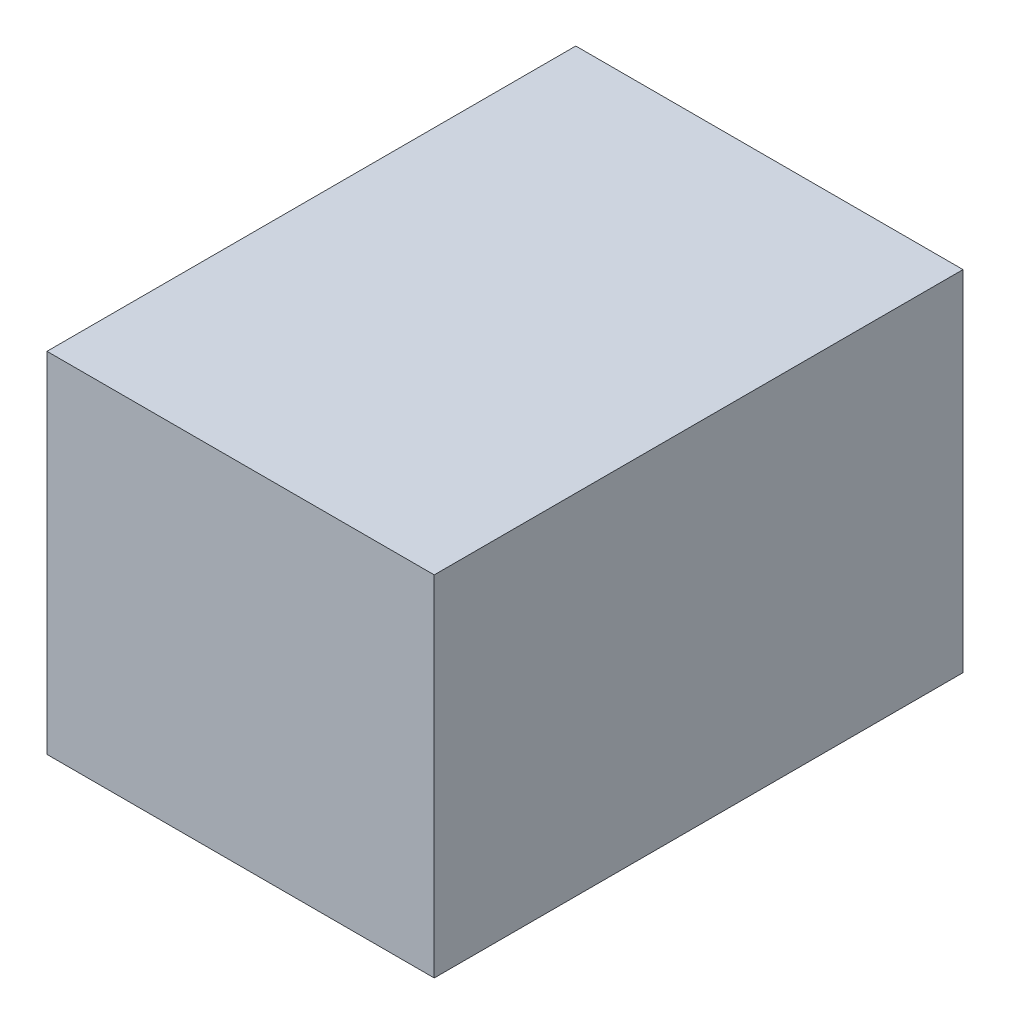
from build123d import *

# Parameters (mm, degrees)
SKETCH1_W           = 12.0904
SKETCH1_H           = 16.51
BOSS_EXTRUDE1_DEPTH = 10.9


with BuildPart() as part:
    # Sketch1 → Boss-Extrude1 (new body)
    with BuildSketch(Plane(origin=(0, 0, 0), x_dir=(1, 0, 0), z_dir=(0, 1, 0))):
        with Locations((6.0452, 8.255)):
            Rectangle(SKETCH1_W, SKETCH1_H)
    extrude(amount=BOSS_EXTRUDE1_DEPTH)


solid = part.part
